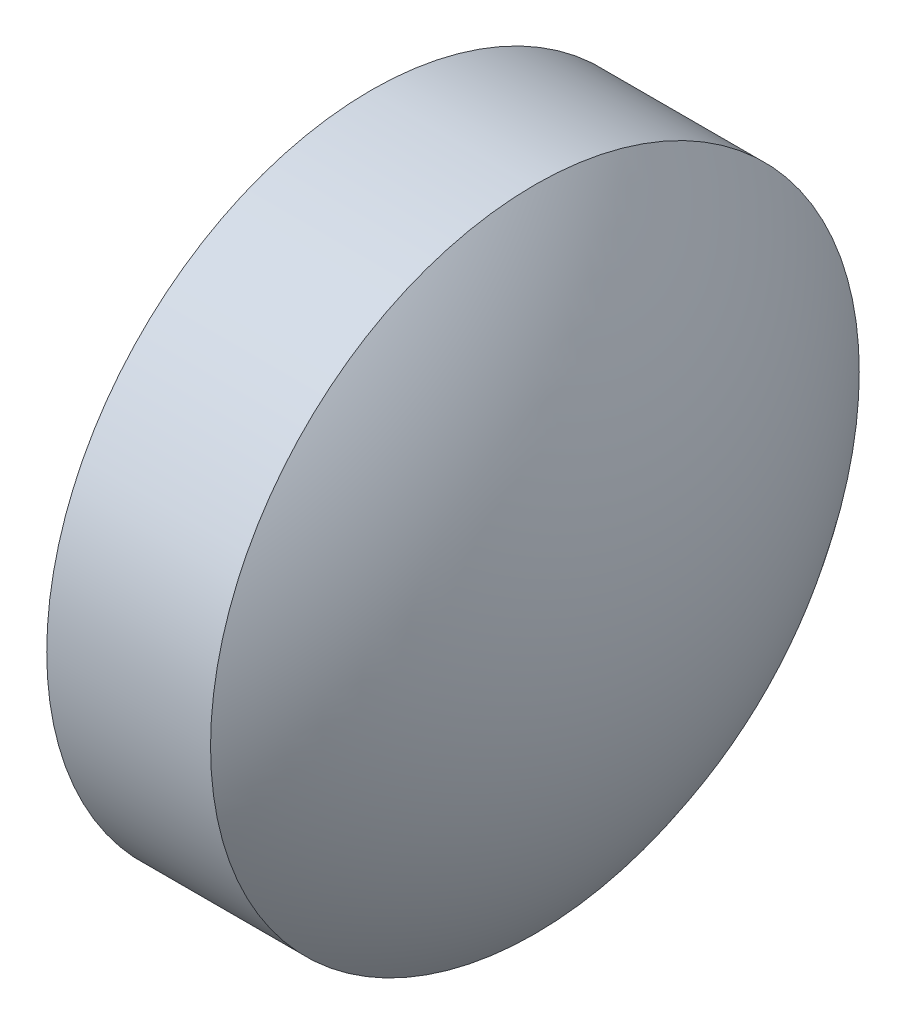
from build123d import *


with BuildPart() as part:
    # 草图1 → 旋转1 (revolve)
    with BuildSketch(Plane.XY, mode=Mode.PRIVATE) as revolve_1_sk:
        with BuildLine():
            Line((389.382727225, 21.685394236), (387.682727225, 21.685394236))
            Line((387.682727225, 21.685394236), (387.682727225, 23.685394236))
            Line((387.682727225, 23.685394236), (388.692727225, 23.685394236))
            ThreePointArc((388.692727225, 23.685394236), (389.205378761, 22.743234016), (389.382727225, 21.685394236))
        make_face()
    revolve(revolve_1_sk.sketch.rotate(Axis((387.335476666, 21.685394236, 0), (1, 0, 0)), 180), axis=Axis((387.335476666, 21.685394236, 0), (1, 0, 0)))  # turned: the seam where the file's is


solid = part.part
